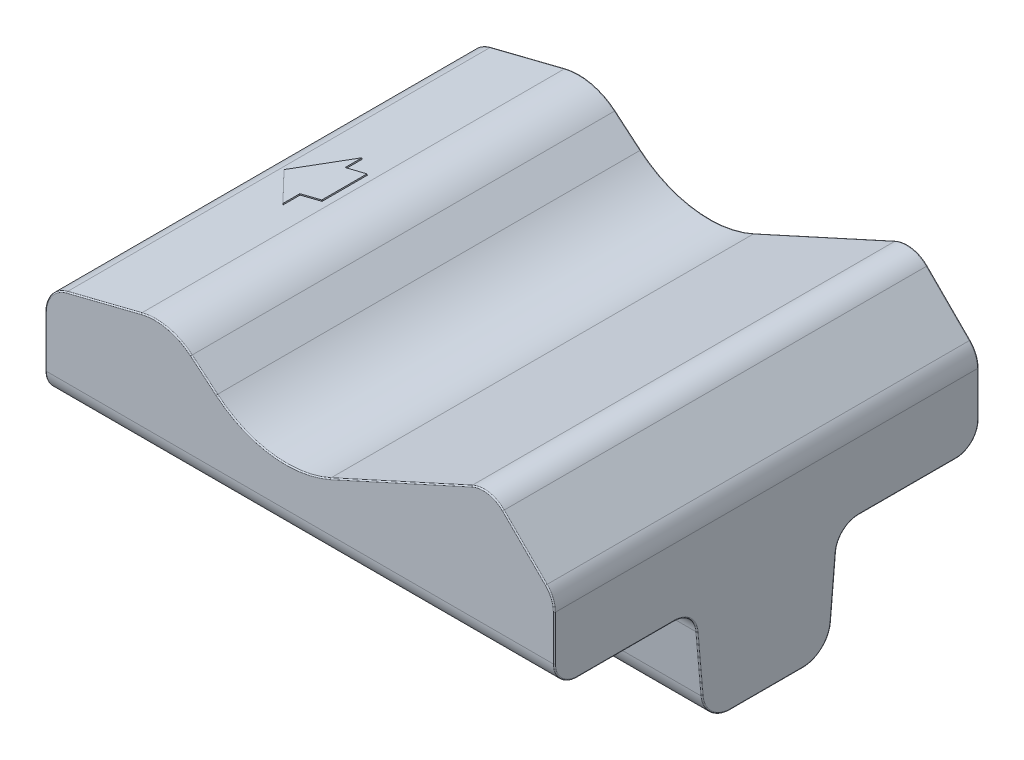
from build123d import *

# Parameters (mm, degrees)
EXTRUDE_1_DEPTH      = 37.5
EXTRUDE_1_DEPTH_BACK = 37.5
MOVE_FACE_3_BY       = 1
EXTRUDE_3_DEPTH      = 90
FILLET_1_R           = 5
FILLET_2_R           = 4
FILLET_3_R           = 5
FILLET_16_R          = 10
EXTRUDE_5_DEPTH      = 6
EXTRUDE_5_DEPTH_BACK = 6
FILLET_14_R          = 2
FILLET_15_R          = 0.2
FILLET_17_R          = 4
FILLET_19_R          = 0.2
EXTRUDE_6_DEPTH      = 0.2


with BuildPart() as part:
    # Sketch 1 → Extrude 1 (new, two sides)
    with BuildSketch(Plane.XY) as extrude_1_sk:
        with BuildLine():
            Line((7.865862361, -17.295323337), (36, -4.5))
            Line((36, -4.5), (47.5, -16))
            Line((47.5, -16), (47.5, -31))
            Line((47.5, -31), (-42.5, -31))
            Line((-42.5, -31), (-42.5, -13))
            Line((-42.5, -13), (-20.620600766, -7.5))
            Line((-20.620600766, -7.5), (-12.212964584, -14.554844419))
            ThreePointArc((-12.212964584, -14.554844419), (-2.569412503, -18.825464653), (7.865862361, -17.295323337))
        make_face()
    extrude(amount=EXTRUDE_1_DEPTH)
    extrude(extrude_1_sk.sketch, amount=-EXTRUDE_1_DEPTH_BACK)

    # Move Face 3: a face moved inward by 1.0
    extrude(part.faces().sort_by_distance((2.5, -31, 0))[0], amount=MOVE_FACE_3_BY, dir=(0, 1, 0), mode=Mode.SUBTRACT)

    # Sketch 4 → Extrude 3 (add)
    with BuildSketch(Plane.ZY.offset(42.5)):
        Polygon((-12.618540275, -30), (-11, -48.5), (11, -48.5), (12.618540275, -30), align=None)
    extrude(amount=-EXTRUDE_3_DEPTH)

    # Fillet 1
    fillet_1_edges = [part.edges().sort_by_distance(p)[0] for p in [
        (36, -4.5, 0),
        (47.5, -16, 0),
        (-42.5, -13, 0),
    ]]
    fillet(fillet_1_edges, radius=FILLET_1_R)

    # Fillet 2
    fillet_2_edges = [part.edges().sort_by_distance(p)[0] for p in [
        (2.5, -30, 12.618540275),
        (2.5, -30, -12.618540275),
    ]]
    fillet(fillet_2_edges, radius=FILLET_2_R)

    # Fillet 3
    fillet_3_edges = [part.edges().sort_by_distance(p)[0] for p in [
        (2.5, -48.5, 11),
        (2.5, -48.5, -11),
    ]]
    fillet(fillet_3_edges, radius=FILLET_3_R)

    # Fillet 16
    fillet_16_edges = [part.edges().sort_by_distance(p)[0] for p in [
        (-20.620600766, -7.5, 0),
    ]]
    fillet(fillet_16_edges, radius=FILLET_16_R)

    # Sketch 9 → Extrude 5 (add, two sides)
    with BuildSketch(Plane(origin=(0, 0, 0), x_dir=(0, 0, -1), z_dir=(1, 0, 0))) as extrude_5_sk:
        with BuildLine():
            Line((15.966352182, -30.01262171), (13.5, -44))
            Line((13.5, -44), (11.393281315, -44))
            ThreePointArc((11.393281315, -44), (11.396403033, -43.967899091), (11.39931762, -43.935778714))
            Line((11.39931762, -43.935778714), (12.299086179, -33.651377029))
            ThreePointArc((12.299086179, -33.651377029), (13.466496823, -31.16055697), (15.966352182, -30.01262171))
        make_face()
        with BuildLine():
            Line((-13.5, -44), (-11.393281315, -44))
            ThreePointArc((-11.393281315, -44), (-11.396403033, -43.967899091), (-11.39931762, -43.935778714))
            Line((-11.39931762, -43.935778714), (-12.299086179, -33.651377029))
            ThreePointArc((-12.299086179, -33.651377029), (-13.466496823, -31.16055697), (-15.966352182, -30.01262171))
            Line((-15.966352182, -30.01262171), (-13.5, -44))
        make_face()
    extrude(amount=EXTRUDE_5_DEPTH)
    extrude(extrude_5_sk.sketch, amount=-EXTRUDE_5_DEPTH_BACK)

    # Fillet 14
    fillet_14_edges = [part.edges().sort_by_distance(p)[0] for p in [
        (-6, -44, -12.446640658),
        (6, -44, -12.446640658),
        (-6, -44, 12.446640658),
        (6, -44, 12.446640658),
    ]]
    fillet(fillet_14_edges, radius=FILLET_14_R)

    # Fillet 15
    fillet_15_edges = [part.edges().sort_by_distance(p)[0] for p in [
        (-6, -31.16055697, -13.466496823),
        (0, -30.01262171, -15.966352182),
        (-6, -37.825688515, -11.933881246),
        (6, -31.16055697, -13.466496823),
        (6, -37.825688515, -11.933881246),
        (0, -30.01262171, 15.966352182),
        (-6, -31.16055697, 13.466496823),
        (-6, -36.006310855, 14.909503072),
        (6, -31.16055697, 13.466496823),
        (6, -36.006310855, 14.909503072),
        (0, -44, 11.393281315),
        (0, -44, 13.5),
        (-6, -37.825688515, 11.933881246),
        (5.419615207, -43.408791206, 13.604246062),
        (-5.419615207, -43.408791206, 13.604246062),
        (6, -37.825688515, 11.933881246),
        (0, -44, -13.5),
        (0, -44, -11.393281315),
        (6, -36.006310855, -14.909503072),
        (-6, -36.006310855, -14.909503072),
        (5.419615207, -43.408791206, -13.604246062),
        (-5.419615207, -43.408791206, -13.604246062),
        (-4.253435662, -43.983877596, 11.394875295),
        (-5.582853257, -43.22252835, 11.461718941),
        (5.582853257, -43.22252835, 11.461718941),
        (4.253435662, -43.983877596, 11.394875295),
        (-5.582853257, -43.22252835, -11.461718941),
        (-4.253435665, -43.983877597, -11.394875292),
        (4.253435665, -43.983877597, -11.394875292),
        (5.582853257, -43.22252835, -11.461718941),
    ]]
    fillet(fillet_15_edges, radius=FILLET_15_R)

    # Fillet 17
    fillet_17_edges = [part.edges().sort_by_distance(p)[0] for p in [
        (2.5, -30, -37.5),
        (2.5, -30, 37.5),
    ]]
    fillet(fillet_17_edges, radius=FILLET_17_R)

    # Fillet 19
    fillet_19_edges = [part.edges().sort_by_distance(p)[0] for p in [
        (-32.146436202, -10.39734166, 37.5),
        (-20.895862525, -8.697558494, 37.5),
        (-32.146436202, -10.39734166, -37.5),
        (-20.895862525, -8.697558494, -37.5),
        (-2.569412503, -18.825464653, 37.5),
        (-14.460531102, -12.668912183, 37.5),
        (47.5, -30, -24.891932486),
        (-42.5, -30, -24.891932486),
        (47.5, -22.035533906, -37.5),
        (47.5, -22.035533906, 37.5),
        (47.5, -28.828427125, 36.328427125),
        (47.5, -28.828427125, -36.328427125),
        (-42.5, -28.828427125, 36.328427125),
        (-42.5, -28.828427125, -36.328427125),
        (-2.569412503, -18.825464653, -37.5),
        (-42.5, -21.449333685, 37.5),
        (42.243103107, -10.743103107, 37.5),
        (20.355518491, -11.615064336, 37.5),
        (-41.443021123, -13.824161812, 37.5),
        (35.806749513, -5.566345481, 37.5),
        (47.119397663, -16.15765065, 37.5),
        (42.243103107, -10.743103107, -37.5),
        (20.355518491, -11.615064336, -37.5),
        (-42.5, -21.449333685, -37.5),
        (-41.443021123, -13.824161812, -37.5),
        (35.806749513, -5.566345481, -37.5),
        (47.119397663, -16.15765065, -37.5),
        (-14.460531102, -12.668912183, -37.5),
        (47.5, -30, 24.891932486),
        (-42.5, -30, 24.891932486),
        (47.5, -38.793577871, -11.8492019),
        (-42.5, -38.793577871, -11.8492019),
        (-42.5, -31.050890653, 13.581504141),
        (47.5, -31.050890653, 13.581504141),
        (-42.5, -31.050890653, -13.581504141),
        (47.5, -31.050890653, -13.581504141),
        (47.5, -48.5, 0),
        (-42.5, -48.5, 0),
        (-42.5, -38.793577871, 11.8492019),
        (-42.5, -47.186386684, -9.796295168),
        (-42.5, -47.186386684, 9.796295168),
        (47.5, -38.793577871, 11.8492019),
        (47.5, -47.186386684, -9.796295168),
        (47.5, -47.186386684, 9.796295168),
    ]]
    fillet(fillet_19_edges, radius=FILLET_19_R)

    # Sketch 5 → Extrude 6 (add)
    with BuildSketch(Plane(origin=(0.547691528, -2.178756653, 0), x_dir=(0.9698272285645214, 0.24379324587621276, 0), z_dir=(-0.24379324587621276, 0.9698272285645214, 0))):
        Polygon((-39.48830204, 0), (-32.48830204, 7), (-32.48830204, 4), (-28.48830204, 4), (-28.48830204, -4), (-32.48830204, -4), (-32.48830204, -7), align=None)
    extrude(amount=EXTRUDE_6_DEPTH)


solid = part.part
